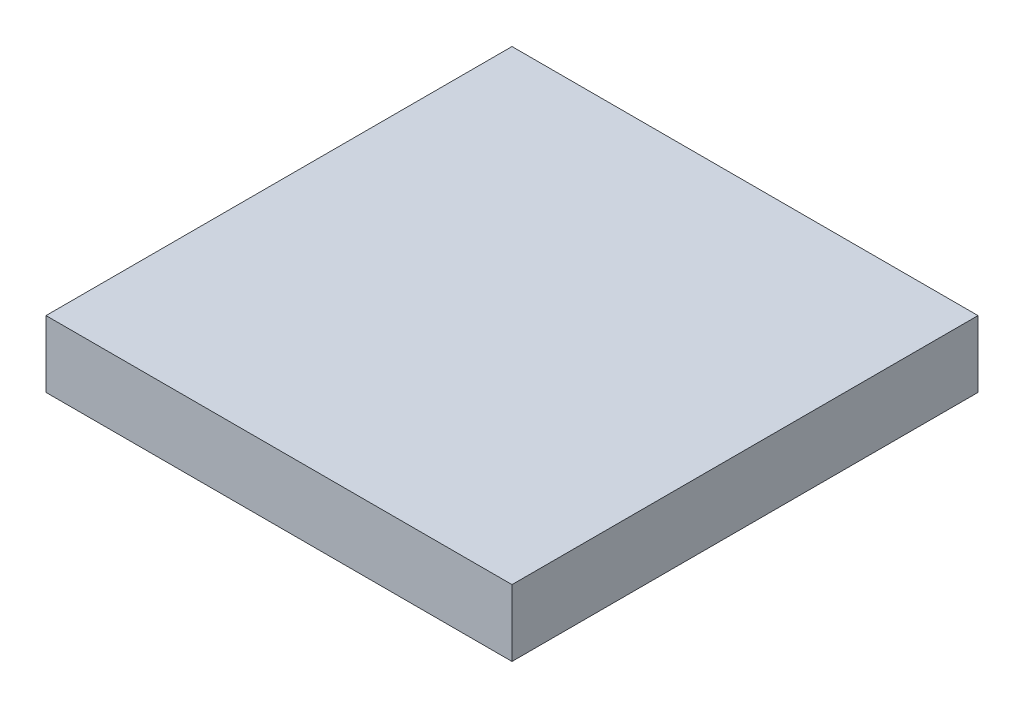
from build123d import *

# Parameters (mm, degrees)
SKETCH1_W           = 350
SKETCH1_H           = 350
BOSS_EXTRUDE1_DEPTH = 50


with BuildPart() as part:
    # Sketch1 → Boss-Extrude1 (new body)
    with BuildSketch(Plane(origin=(0, 0, 0), x_dir=(1, 0, 0), z_dir=(0, 1, 0))):
        with Locations((85.257298601, 120.542497106)):
            Rectangle(SKETCH1_W, SKETCH1_H)
    extrude(amount=-BOSS_EXTRUDE1_DEPTH)


solid = part.part
